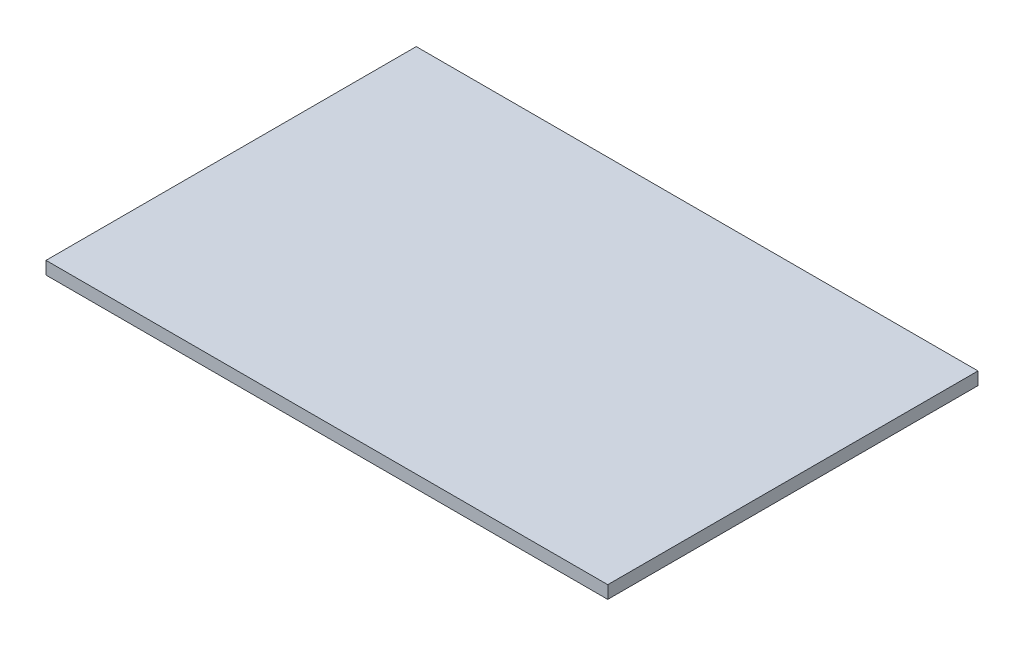
from build123d import *

# Parameters (mm, degrees)
SKETCH1_W           = 220
SKETCH1_H           = 145
BOSS_EXTRUDE1_DEPTH = 5


with BuildPart() as part:
    # Sketch1 → Boss-Extrude1 (new body)
    with BuildSketch(Plane(origin=(0, 0, 0), x_dir=(1, 0, 0), z_dir=(0, 1, 0))):
        with Locations((110, 72.5)):
            Rectangle(SKETCH1_W, SKETCH1_H)
    extrude(amount=BOSS_EXTRUDE1_DEPTH)


solid = part.part
